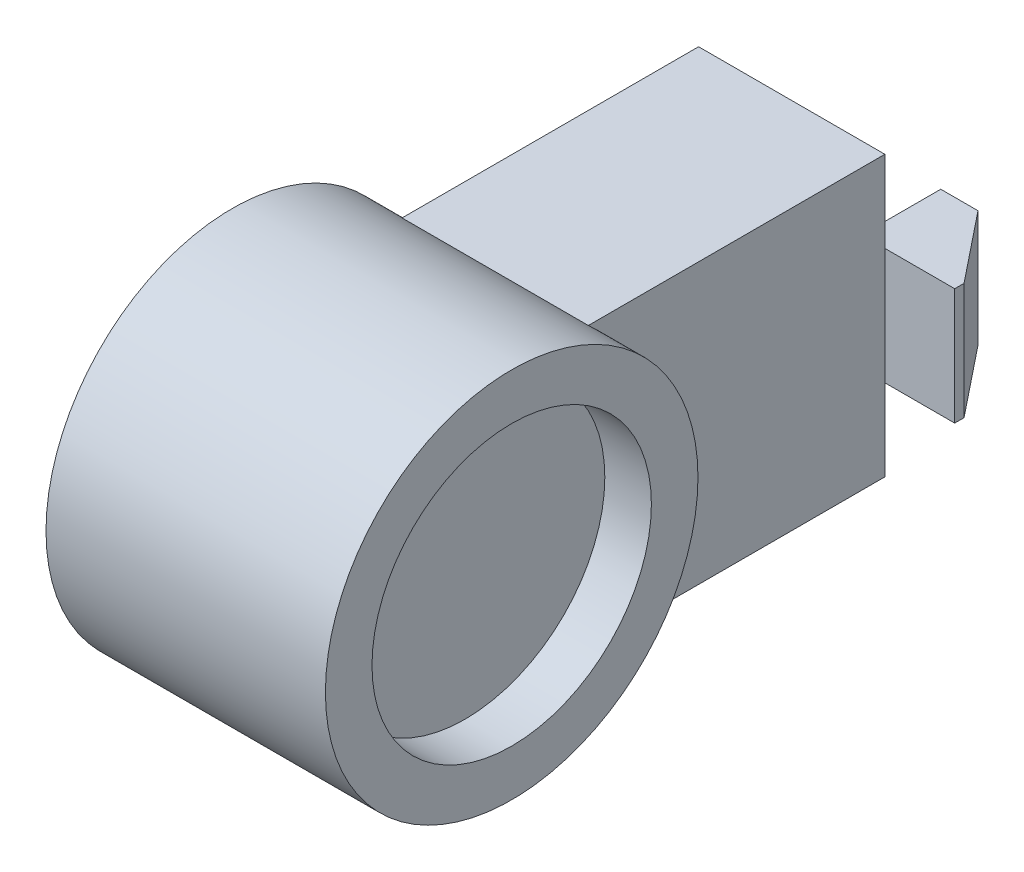
from build123d import *

# Parameters (mm, degrees)
SKETCH1_R           = 40
BOSS_EXTRUDE1_DEPTH = 60
BOSS_EXTRUDE3_REACH = 132.133
SKETCH2_W           = 40
SKETCH2_H           = 60
SKETCH3_W           = 70
SKETCH3_H           = 25
BOSS_EXTRUDE4_DEPTH = 2
BOSS_EXTRUDE5_DEPTH = 25
SKETCH8_R           = 30
CUT_EXTRUDE3_DEPTH  = 10
SKETCH9_R           = 6
CUT_EXTRUDE4_DEPTH  = 6


with BuildPart() as part:
    # Sketch1 → Boss-Extrude1 (new body)
    with BuildSketch(Plane(origin=(0, 0, 0), x_dir=(0, 0, -1), z_dir=(1, 0, 0))):
        Circle(SKETCH1_R)
    extrude(amount=BOSS_EXTRUDE1_DEPTH)

    # Sketch2 → Boss-Extrude3 (add, up to next)
    with BuildSketch(Plane.XY.offset(-90.13280569), mode=Mode.PRIVATE) as boss_extrude3_sk1:
        with Locations((30, 0)):
            Rectangle(SKETCH2_W, SKETCH2_H)
    boss_extrude3_tool1 = extrude(boss_extrude3_sk1.sketch, amount=BOSS_EXTRUDE3_REACH, mode=Mode.PRIVATE) - part.part
    add(boss_extrude3_tool1.solids().sort_by_distance((30, 0, -90.132806))[0])

    # Sketch3 → Boss-Extrude4 (add)
    with BuildSketch(Plane(origin=(0, 0, -90.13280569), x_dir=(-1, 0, 0), z_dir=(0, 0, -1))):
        with Locations((-30, 0)):
            Rectangle(SKETCH3_W, SKETCH3_H)
    extrude(amount=BOSS_EXTRUDE4_DEPTH)

    # Sketch5 → Boss-Extrude5 (add)
    with BuildSketch(Plane(origin=(0, 12.5, 0), x_dir=(1, 0, 0), z_dir=(0, 1, 0))):
        Polygon((-5, 92.13280569), (7, 107.13280569), (15, 107.13280569), (15, 92.13280569), align=None)
        Polygon((45, 107.13280569), (45, 92.13280569), (65, 92.13280569), (53, 107.13280569), align=None)
    extrude(amount=-BOSS_EXTRUDE5_DEPTH)

    # Sketch8 → Cut-Extrude3 (cut)
    with BuildSketch(Plane(origin=(60, 0, 0), x_dir=(0, 0, -1), z_dir=(1, 0, 0))):
        Circle(SKETCH8_R)
    extrude(amount=-CUT_EXTRUDE3_DEPTH, mode=Mode.SUBTRACT)

    # Sketch9 → Cut-Extrude4 (cut)
    with BuildSketch(Plane.ZY):
        Circle(SKETCH9_R)
    extrude(amount=-CUT_EXTRUDE4_DEPTH, mode=Mode.SUBTRACT)


solid = part.part
